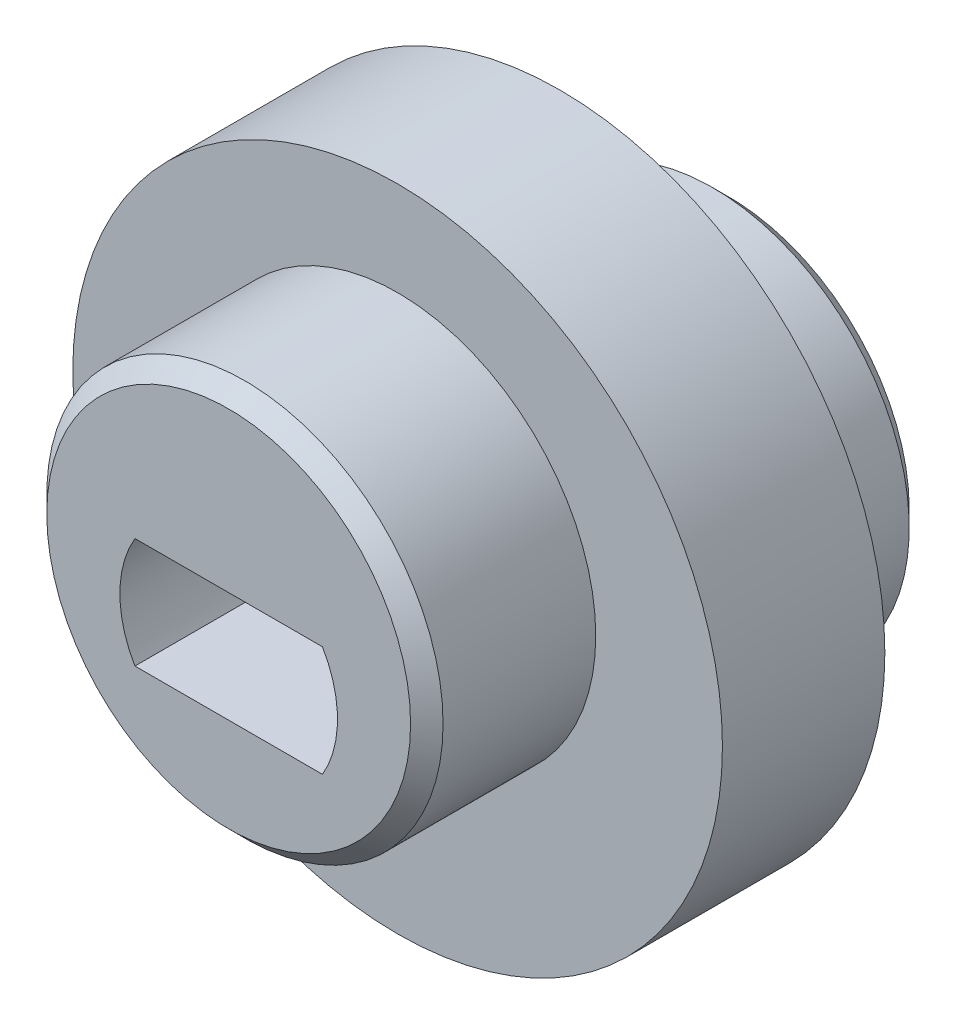
from build123d import *

# Parameters (mm, degrees)
SKETCH6_R               = 6
BOSS_EXTRUDE4_DEPTH     = 2.5
SKETCH7_R               = 6.1
BOSS_EXTRUDE5_DEPTH     = 5.2
SKETCH8_R               = 6.05
BOSS_EXTRUDE6_DEPTH     = 5.2
SKETCH13_R              = 10
BOSS_EXTRUDE7_DEPTH     = 5
CUT_EXTRUDE1_DEPTH      = 6.2
CUT_EXTRUDE1_DEPTH_BACK = 11.2
CHAMFER1_SIZE           = 0.5


with BuildPart() as part:
    # Sketch6 → Boss-Extrude4 (new body, symmetric)
    with BuildSketch(Plane.XY):
        Circle(SKETCH6_R)
    extrude(amount=BOSS_EXTRUDE4_DEPTH, both=True)

    # Sketch7 → Boss-Extrude5 (add)
    with BuildSketch(Plane.XY.offset(2.5)):
        with Locations((0, 1)):
            Circle(SKETCH7_R)
    extrude(amount=BOSS_EXTRUDE5_DEPTH)

    # Sketch8 → Boss-Extrude6 (add)
    with BuildSketch(Plane(origin=(0, 0, -2.5), x_dir=(-1, 0, 0), z_dir=(0, 0, -1))):
        with Locations((0, -1)):
            Circle(SKETCH8_R)
    extrude(amount=BOSS_EXTRUDE6_DEPTH)

    # Sketch13 → Boss-Extrude7 (add)
    with BuildSketch(Plane.XY.offset(2.5)):
        Circle(SKETCH13_R)
    extrude(amount=-BOSS_EXTRUDE7_DEPTH)

    # Sketch11 → Cut-Extrude1 (cut, two sides)
    with BuildSketch(Plane.XY.offset(2.5)) as cut_extrude1_sk:
        with BuildLine():
            Line((-2.886607005, -1.7), (2.886607005, -1.7))
            ThreePointArc((2.886607005, -1.7), (3.35, 0), (2.886607005, 1.7))
            Line((2.886607005, 1.7), (-2.886607005, 1.7))
            ThreePointArc((-2.886607005, 1.7), (-3.35, 0), (-2.886607005, -1.7))
        make_face()
    extrude(amount=CUT_EXTRUDE1_DEPTH, mode=Mode.SUBTRACT)
    extrude(cut_extrude1_sk.sketch, amount=-CUT_EXTRUDE1_DEPTH_BACK, mode=Mode.SUBTRACT)

    # Chamfer1
    chamfer1_edges = [part.edges().sort_by_distance(p)[0] for p in [
        (6.05, -1, -7.7),
        (-6.1, 1, 7.7),
    ]]
    chamfer(chamfer1_edges, length=CHAMFER1_SIZE)


solid = part.part
